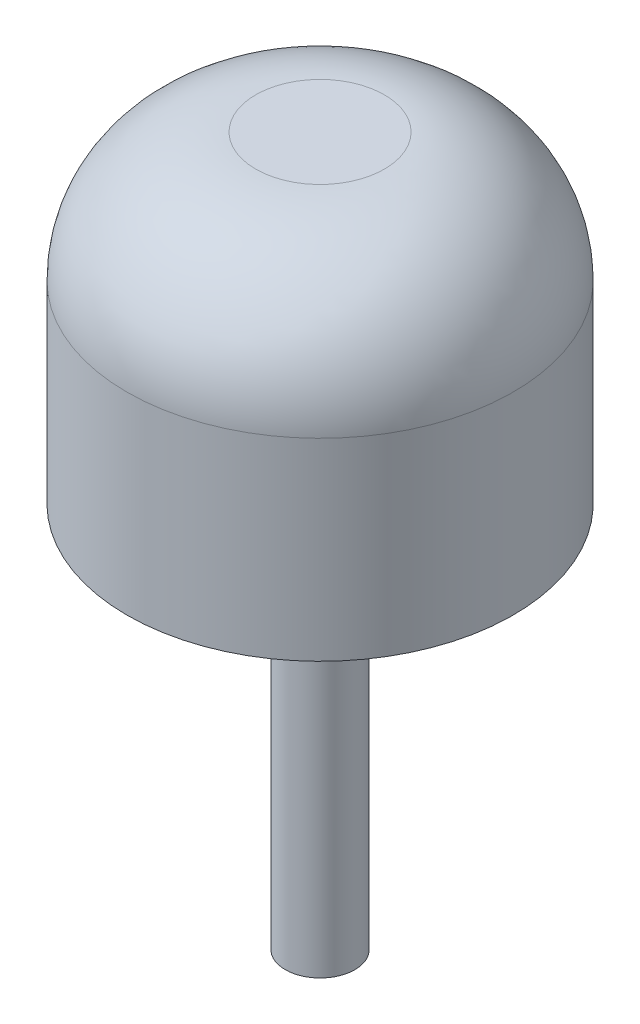
from build123d import *

# Parameters (mm, degrees)
SKETCH1_R           = 3.81
BOSS_EXTRUDE1_DEPTH = 6.35
SKETCH2_R           = 0.6858
BOSS_EXTRUDE2_DEPTH = 7.62
FILLET1_R           = 2.54


with BuildPart() as part:
    # Sketch1 → Boss-Extrude1 (new body)
    with BuildSketch(Plane(origin=(0, 0, 0), x_dir=(1, 0, 0), z_dir=(0, 1, 0))):
        Circle(SKETCH1_R)
    extrude(amount=BOSS_EXTRUDE1_DEPTH)

    # Sketch2 → Boss-Extrude2 (add)
    with BuildSketch(Plane.XZ):
        Circle(SKETCH2_R)
    extrude(amount=BOSS_EXTRUDE2_DEPTH)

    # Fillet1
    fillet1_edges = [part.edges().sort_by_distance(p)[0] for p in [
        (-3.81, 6.35, 0),
    ]]
    fillet(fillet1_edges, radius=FILLET1_R)


solid = part.part
